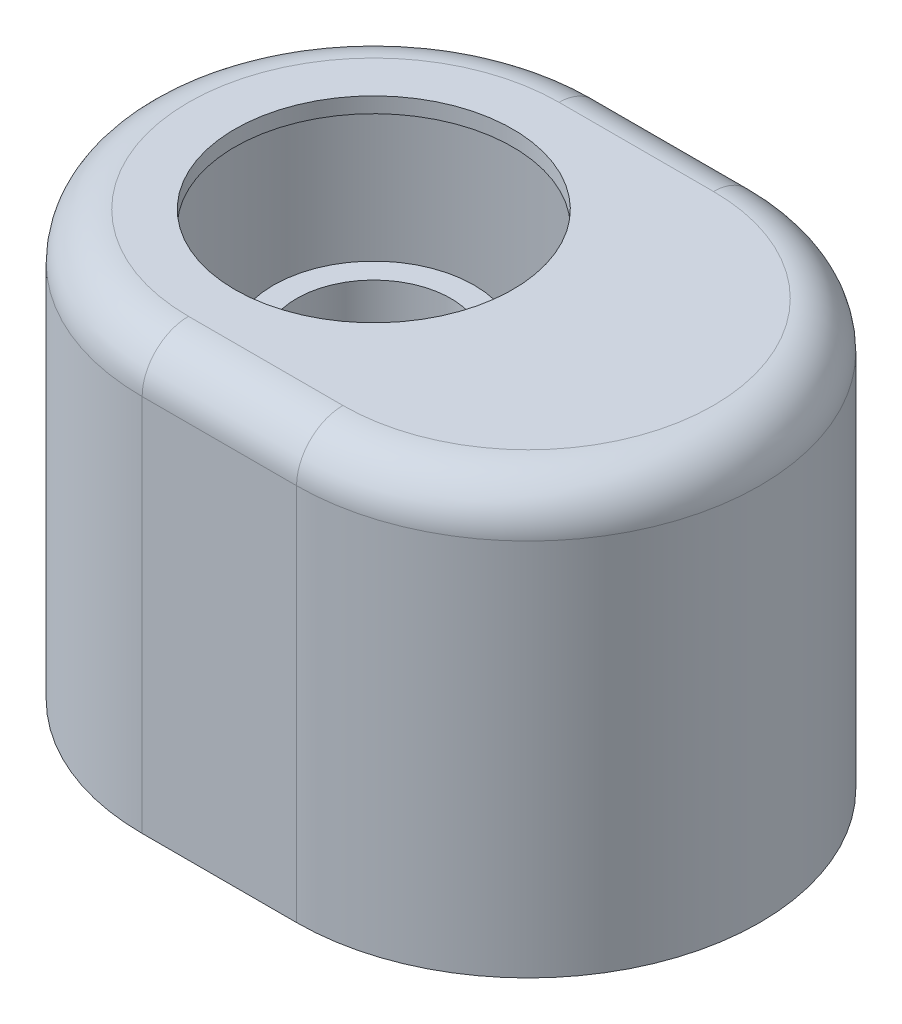
from build123d import *

# Parameters (mm, degrees)
EXTRUDE_1_DEPTH     = 55
FILLET_1_R          = 6
SHELL_1_T           = -2
SKETCH_2_R          = 18
CUT_EXTRUDE_1_DEPTH = 56


with BuildPart() as part:
    # 草图1 → 凸台-拉伸1 (new body)
    with BuildSketch(Plane(origin=(0, 0, 0), x_dir=(1, 0, 0), z_dir=(0, 1, 0))):
        with BuildLine():
            Line((0, 30), (20, 30))
            ThreePointArc((20, 30), (50, 0), (20, -30))
            Line((20, -30), (0, -30))
            ThreePointArc((0, -30), (-30, 0), (0, 30))
        make_face()
    extrude(amount=EXTRUDE_1_DEPTH)

    # 圆角1
    fillet_1_edges = [part.edges().sort_by_distance(p)[0] for p in [
        (50, 55, 0),
        (10, 55, -30),
        (-30, 55, 0),
        (10, 55, 30),
    ]]
    fillet(fillet_1_edges, radius=FILLET_1_R)

    # 抽壳1
    shell_1_openings = [part.faces().sort_by_distance(p)[0] for p in [
        (10, 0, 0),
    ]]
    offset(amount=SHELL_1_T, openings=shell_1_openings, kind=Kind.INTERSECTION)

    # 草图2 → 切除-拉伸1 (cut, through all)
    with BuildSketch(Plane(origin=(0, 55, 0), x_dir=(1, 0, 0), z_dir=(0, 1, 0))):
        Circle(SKETCH_2_R)
    extrude(amount=-CUT_EXTRUDE_1_DEPTH, mode=Mode.SUBTRACT)


with BuildPart() as body_2:
    # 草图3 → 旋转1 (revolve)
    with BuildSketch(Plane.XY):
        Polygon((-10, 40), (-13, 40), (-13, 32.632889149), (-9.5, 26.632889149), (-9.5, 20), (-6.5, 20), (-6.5, 24), (-4.5, 24), (-4.5, 26), (-8, 32), (-8, 34), (-10, 34), align=None)
    revolve(axis=Axis((0, 40, 0), (0, -1, 0)))


solid = Compound([part.part, body_2.part])
